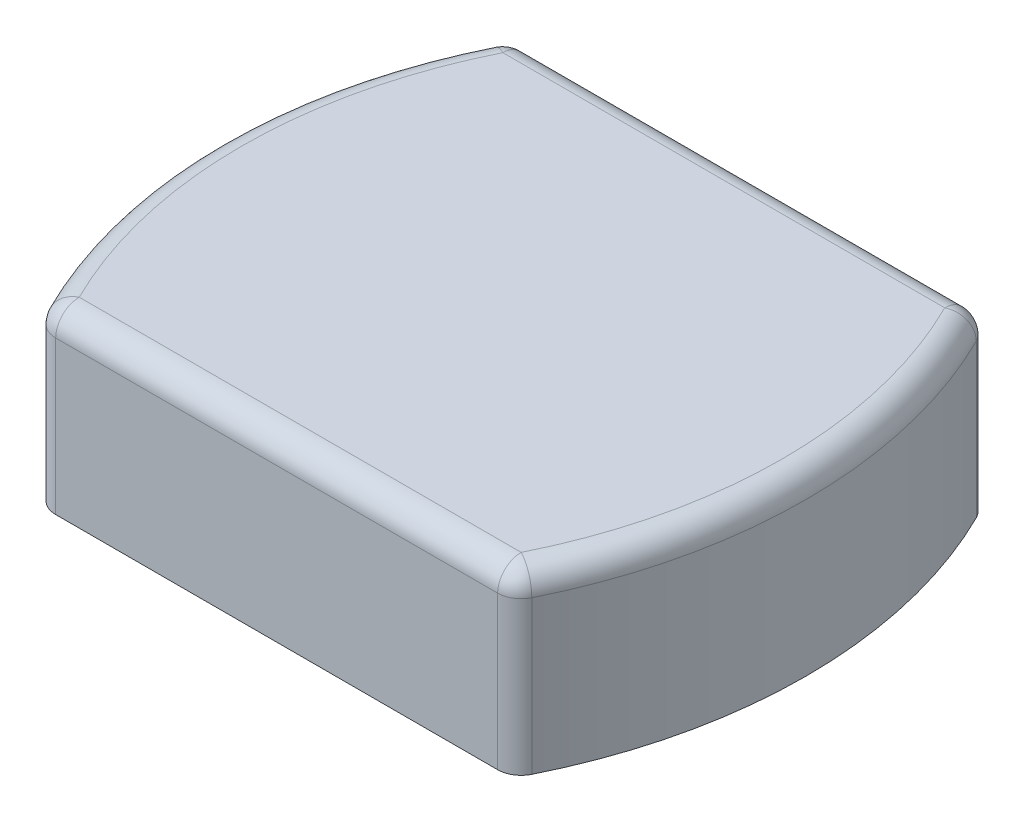
from build123d import *

# Parameters (mm, degrees)
SKETCH1_W           = 50.8
SKETCH1_H           = 50.8
BOSS_EXTRUDE1_DEPTH = 19.05
SKETCH2_W           = 45.72
SKETCH2_H           = 40.64
CUT_EXTRUDE1_DEPTH  = 15.875
FILLET1_R           = 2.54


with BuildPart() as part:
    # Sketch1 → Boss-Extrude1 (new body)
    with BuildSketch(Plane(origin=(0, 0, 0), x_dir=(1, 0, 0), z_dir=(0, 1, 0))):
        with BuildLine():
            ThreePointArc((-25.4, -25.4), (-31.75, 0), (-25.4, 25.4))
            Line((-25.4, 25.4), (-25.4, -25.4))
        make_face()
        with BuildLine():
            ThreePointArc((25.4, 25.4), (31.75, 0), (25.4, -25.4))
            Line((25.4, -25.4), (25.4, 25.4))
        make_face()
        Rectangle(SKETCH1_W, SKETCH1_H)
    extrude(amount=BOSS_EXTRUDE1_DEPTH)

    # Sketch2 → Cut-Extrude1 (cut)
    with BuildSketch(Plane.XZ):
        Rectangle(SKETCH2_W, SKETCH2_H)
    extrude(amount=-CUT_EXTRUDE1_DEPTH, mode=Mode.SUBTRACT)

    # Fillet1
    fillet1_edges = [part.edges().sort_by_distance(p)[0] for p in [
        (31.75, 19.05, 0),
        (0, 19.05, -25.4),
        (-31.75, 19.05, 0),
        (0, 19.05, 25.4),
        (-25.4, 9.525, -25.4),
        (25.4, 9.525, -25.4),
        (25.4, 9.525, 25.4),
        (-25.4, 9.525, 25.4),
    ]]
    fillet(fillet1_edges, radius=FILLET1_R)


solid = part.part
